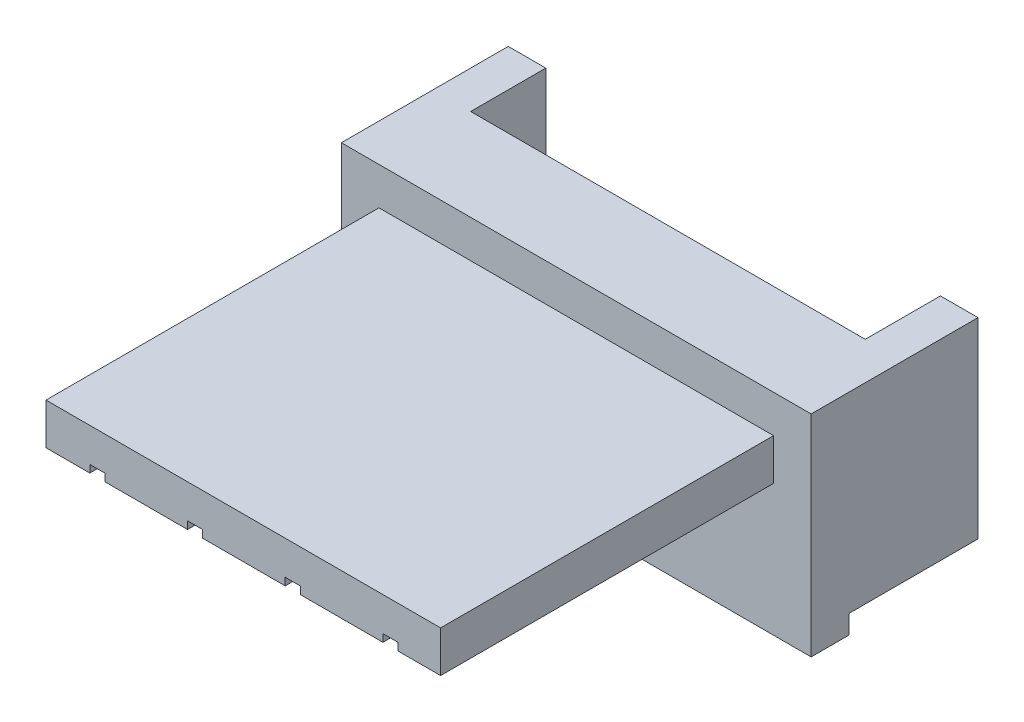
from build123d import *

# Parameters (mm, degrees)
SKETCH_1_W             = 6.25
SKETCH_1_H             = 5.1
EXTRUDE_1_DEPTH        = 13.3
SKETCH_2_W             = 6.25
SKETCH_2_H             = 8.86
CUT_EXTRUDE_1_DEPTH    = 3
SKETCH_7_W             = 12.5
SKETCH_7_H             = 8.86
CUT_EXTRUDE_2_DEPTH    = 1
SKETCH_8_W             = 12.5
SKETCH_8_H             = 1.005646511
EXTRUDE_2_DEPTH        = 0.5
SKETCH_9_W             = 1
SKETCH_9_H             = 1.1
CUT_EXTRUDE_3_DEPTH    = 8.86
SKETCH_6_W             = 0.4
SKETCH_6_H             = 0.4
PATTERN_LINEAR_1_COUNT = 4
PATTERN_LINEAR_1_PITCH = 2.6
SKETCH_10_W            = 10.5
SKETCH_10_H            = 3
CUT_EXTRUDE_4_DEPTH    = 2


with BuildPart() as part:
    # Эскиз1 → Бобышка-Вытянуть1 (new body)
    with BuildSketch(Plane.XY):
        with Locations((-3.125, 2.55)):
            Rectangle(SKETCH_1_W, SKETCH_1_H)
    extrude(amount=-EXTRUDE_1_DEPTH)

    # Эскиз2 → Вырез-Вытянуть1 (cut)
    with BuildSketch(Plane.XZ):
        with Locations((-3.125, -4.43)):
            Rectangle(SKETCH_2_W, SKETCH_2_H)
    extrude(amount=-CUT_EXTRUDE_1_DEPTH, mode=Mode.SUBTRACT)

    # Зеркальное отражение1: part across plane


with BuildPart() as part_1:
    add(part.part)
    add(part.part.mirror(Plane(origin=(0, 5.1, -13.3), x_dir=(0, 0, 1), z_dir=(1, 0, 0))))

    # Эскиз7 → Вырез-Вытянуть2 (cut)
    with BuildSketch(Plane(origin=(0, 5.1, 0), x_dir=(1, 0, 0), z_dir=(0, 1, 0))):
        with Locations((0, 4.43)):
            Rectangle(SKETCH_7_W, SKETCH_7_H)
    extrude(amount=-CUT_EXTRUDE_2_DEPTH, mode=Mode.SUBTRACT)

    # Эскиз8 → Бобышка-Вытянуть2 (add)
    with BuildSketch(Plane(origin=(0, 0, 0), x_dir=(-1, 0, 0), z_dir=(0, -1, 0))):
        with Locations((0, 9.362823256)):
            Rectangle(SKETCH_8_W, SKETCH_8_H)
    extrude(amount=EXTRUDE_2_DEPTH)

    # Эскиз9 → Вырез-Вытянуть3 (cut)
    with BuildSketch(Plane.XY):
        with Locations((5.75, 3.55)):
            Rectangle(SKETCH_9_W, SKETCH_9_H)
        with Locations((-5.75, 3.55)):
            Rectangle(SKETCH_9_W, SKETCH_9_H)
    extrude(amount=-CUT_EXTRUDE_3_DEPTH, mode=Mode.SUBTRACT)

    # Вырез-По траектории1: sweep along a curve in space
    with BuildLine() as sweep_1_path:
        Line((-3.88435792, 3, 0), (-3.88435792, 3, -13.1))
        Line((-3.88435792, 3, -13.1), (-3.88435792, -0.439783166, -13.1))
    # Эскиз6 → Вырез-По траектории1 (sweep, cut)
    with BuildSketch(Plane.XY):
        with Locations((-3.88435792, 3)):
            Rectangle(SKETCH_6_W, SKETCH_6_H)
    sweep_1 = sweep(path=sweep_1_path.line, transition=Transition.RIGHT, mode=Mode.SUBTRACT)

    # Линейный массив1: Вырез-По траектории1 ×4
    with Locations(*[(i * PATTERN_LINEAR_1_PITCH, 0, 0) for i in range(1, PATTERN_LINEAR_1_COUNT)]):
        add(sweep_1, mode=Mode.SUBTRACT)

    # Эскиз10 → Вырез-Вытянуть4 (cut)
    with BuildSketch(Plane(origin=(0, 0, -13.3), x_dir=(-1, 0, 0), z_dir=(0, 0, -1))):
        with Locations((0, 3.6)):
            Rectangle(SKETCH_10_W, SKETCH_10_H)
    extrude(amount=-CUT_EXTRUDE_4_DEPTH, mode=Mode.SUBTRACT)


solid = part_1.part
